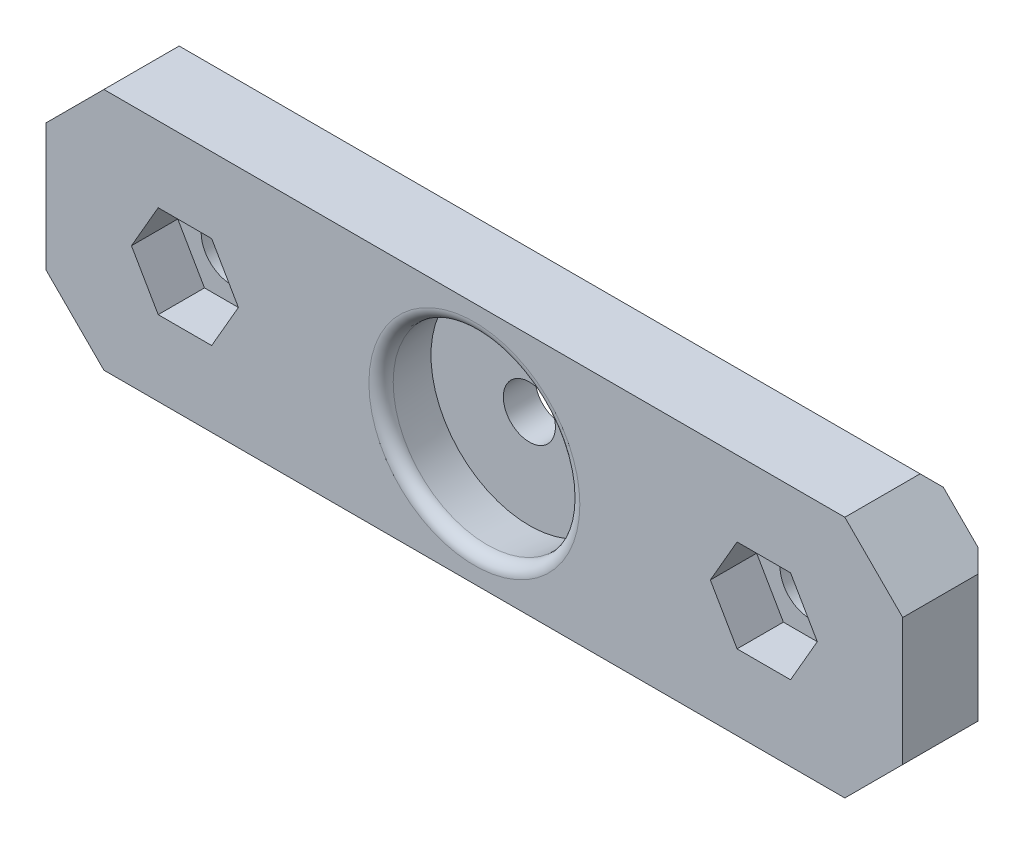
from build123d import *

# Parameters (mm, degrees)
SKETCH1_W           = 74
SKETCH1_H           = 21
BOSS_EXTRUDE1_DEPTH = 7.5
SKETCH2_R           = 8
CUT_EXTRUDE1_DEPTH  = 4.75
CUT_EXTRUDE1_TAPER  = -6
SKETCH4_R           = 2.6
CUT_EXTRUDE4_DEPTH  = 8.5000001
CHAMFER3_SIZE       = 5
CUT_EXTRUDE6_DEPTH  = 4
SKETCH11_R          = 2.25
CUT_EXTRUDE10_DEPTH = 8.5
FILLET4_R           = 1
FILLET5_R           = 1
CHAMFER5_SIZE       = 1


with BuildPart() as part:
    # Sketch1 → Boss-Extrude1 (new body)
    with BuildSketch(Plane.XY):
        Rectangle(SKETCH1_W, SKETCH1_H)
    extrude(amount=BOSS_EXTRUDE1_DEPTH)

    # Sketch2 → Cut-Extrude1 (cut)
    with BuildSketch(Plane.XY.offset(7.5)):
        Circle(SKETCH2_R)
    extrude(amount=-CUT_EXTRUDE1_DEPTH, taper=CUT_EXTRUDE1_TAPER, mode=Mode.SUBTRACT)

    # Sketch4 → Cut-Extrude4 (cut, through all)
    with BuildSketch(Plane(origin=(0, 0, 0), x_dir=(-1, 0, 0), z_dir=(0, 0, -1))):
        with Locations((-25, 0)):
            Circle(SKETCH4_R)
        with Locations((25, 0)):
            Circle(SKETCH4_R)
    extrude(amount=-CUT_EXTRUDE4_DEPTH, mode=Mode.SUBTRACT)

    # Chamfer3
    chamfer3_edges = [part.edges().sort_by_distance(p)[0] for p in [
        (37, -10.5, 3.75),
        (-37, -10.5, 3.75),
        (-37, 10.5, 3.75),
        (37, 10.5, 3.75),
    ]]
    chamfer(chamfer3_edges, length=CHAMFER3_SIZE)

    # Sketch5 → Cut-Extrude6 (cut)
    with BuildSketch(Plane.XY.offset(7.5)):
        Polygon((22.690598923, -4), (27.309401077, -4), (29.618802154, 0), (27.309401077, 4), (22.690598923, 4), (20.381197846, 0), align=None)
        Polygon((-27.309401077, -4), (-22.690598923, -4), (-20.381197846, 0), (-22.690598923, 4), (-27.309401077, 4), (-29.618802154, 0), align=None)
    extrude(amount=-CUT_EXTRUDE6_DEPTH, mode=Mode.SUBTRACT)

    # Sketch11 → Cut-Extrude10 (cut, through all)
    with BuildSketch(Plane.XY.offset(7.5)):
        Circle(SKETCH11_R)
    extrude(amount=-CUT_EXTRUDE10_DEPTH, mode=Mode.SUBTRACT)

    # Fillet4
    fillet4_edges = [part.edges().sort_by_distance(p)[0] for p in [
        (27.6, 0, 0),
        (-22.4, 0, 0),
    ]]
    fillet(fillet4_edges, radius=FILLET4_R)

    # Fillet5
    fillet5_edges = [part.edges().sort_by_distance(p)[0] for p in [
        (-8, 0, 7.5),
    ]]
    fillet(fillet5_edges, radius=FILLET5_R)

    # Chamfer5
    chamfer5_edges = [part.edges().sort_by_distance(p)[0] for p in [
        (-37, 0, 0),
        (37, 0, 0),
        (0, -10.5, 0),
        (0, 10.5, 0),
    ]]
    chamfer(chamfer5_edges, length=CHAMFER5_SIZE)


solid = part.part
